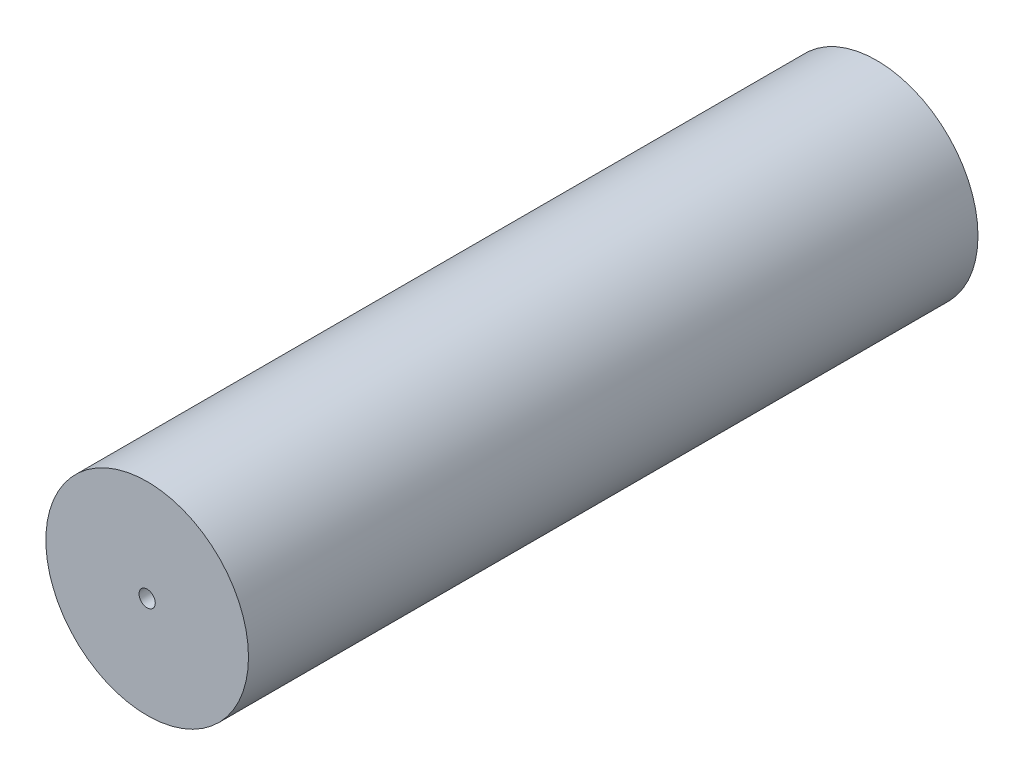
from build123d import *

# Parameters (mm, degrees)
SKETCH1_R           = 125
BOSS_EXTRUDE1_DEPTH = 900
SKETCH2_R           = 10
CUT_EXTRUDE1_DEPTH  = 350
SKETCH3_R           = 10
CUT_EXTRUDE2_DEPTH  = 400


with BuildPart() as part:
    # Sketch1 → Boss-Extrude1 (new body)
    with BuildSketch(Plane.XY):
        Circle(SKETCH1_R)
    extrude(amount=BOSS_EXTRUDE1_DEPTH)

    # Sketch2 → Cut-Extrude1 (cut)
    with BuildSketch(Plane.XY.offset(900)):
        Circle(SKETCH2_R)
    extrude(amount=-CUT_EXTRUDE1_DEPTH, mode=Mode.SUBTRACT)

    # Sketch3 → Cut-Extrude2 (cut)
    with BuildSketch(Plane(origin=(0, 0, 0), x_dir=(-1, 0, 0), z_dir=(0, 0, -1))):
        Circle(SKETCH3_R)
    extrude(amount=-CUT_EXTRUDE2_DEPTH, mode=Mode.SUBTRACT)


solid = part.part
